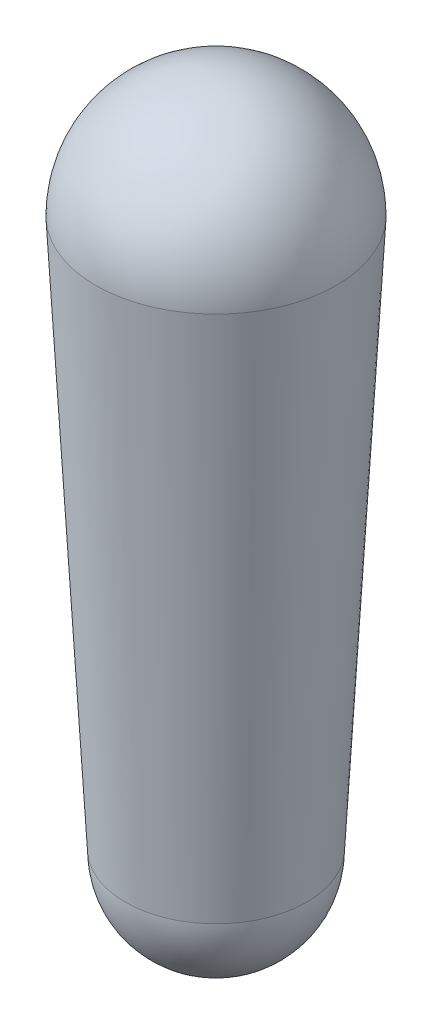
from build123d import *

# Parameters (mm, degrees)
SKETCH1_R = 90.957734813
SKETCH2_R = 68.723621859


with BuildPart() as part:
    # Sketch1 → Loft1 section 0
    with BuildSketch(Plane(origin=(0, 0, 0), x_dir=(1, 0, 0), z_dir=(0, 1, 0))):
        Circle(SKETCH1_R)
    # Sketch2 → Loft1 section 1
    with BuildSketch(Plane(origin=(0, -415.036, 0), x_dir=(-1, 0, 0), z_dir=(0, 1, 0))):
        Circle(SKETCH2_R)
    loft()

    # Sketch5 → Revolve1 (revolve)
    with BuildSketch(Plane(origin=(0, 0, 0), x_dir=(0, 0, -1), z_dir=(1, 0, 0))):
        with BuildLine():
            Line((0, -483.759621859), (0, -415.036))
            Line((0, -415.036), (-68.723621859, -415.036))
            ThreePointArc((-68.723621859, -415.036), (-48.594939044, -463.630939044), (0, -483.759621859))
        make_face()
        with BuildLine():
            Line((0, 90.957734813), (0, 0))
            Line((0, 0), (-90.957734813, 0))
            ThreePointArc((-90.957734813, 0), (-64.316831088, 64.316831088), (0, 90.957734813))
        make_face()
    revolve(axis=Axis((0, 0, 0), (0, -1, 0)))


solid = part.part
